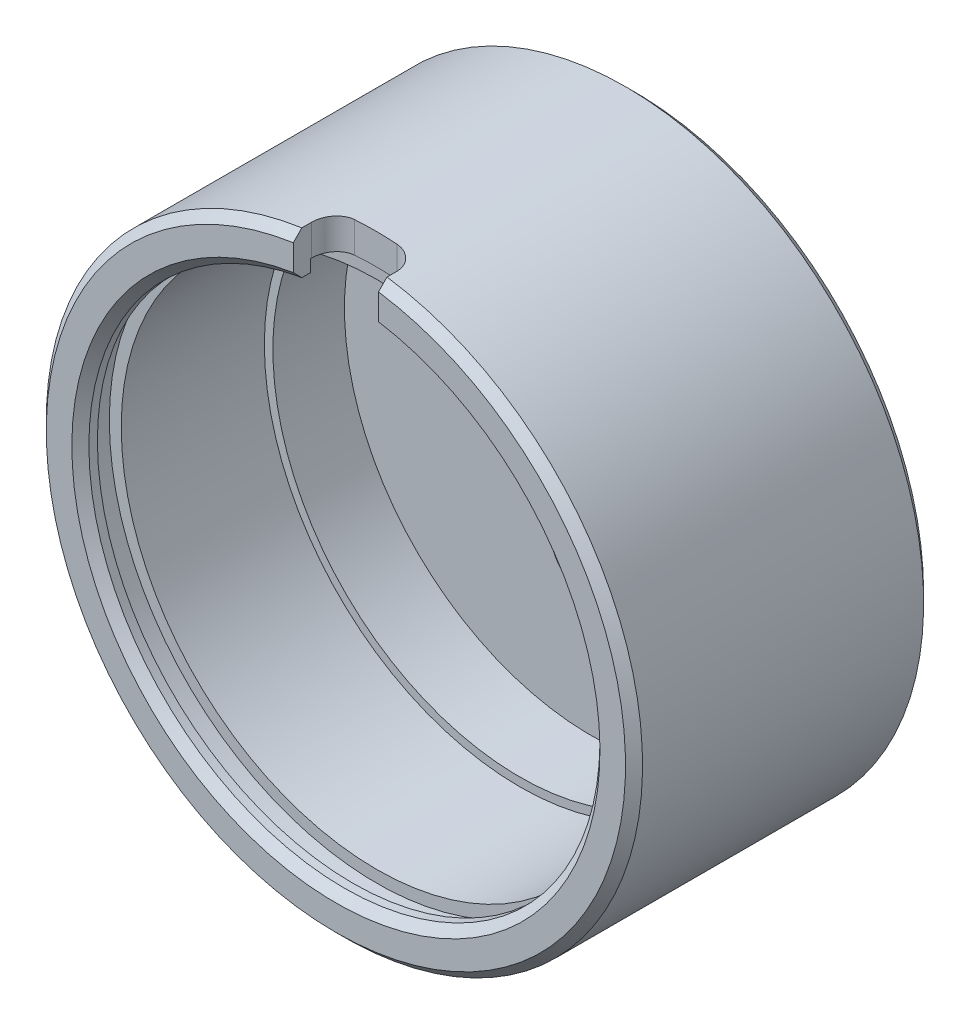
from build123d import *

# Parameters (mm, degrees)
CUT_EXTRUDE1_REACH                                   = 90.9
CHAMFER2_SIZE                                        = 1.27
CHAMFER3_SIZE                                        = 1.27
F_38_0_1015_DIAMETER_HOLE1_D                         = 2.5781
F_38_0_1015_DIAMETER_HOLE1_DEPTH                     = 0.254
F_38_0_1015_DIAMETER_HOLE1_TIP                       = 0.774539381
CBORE_FOR_3_8_BINDING_HEAD_MACHINE_SCREW_D           = 10.3124
CBORE_FOR_3_8_BINDING_HEAD_MACHINE_SCREW_DEPTH       = 6.35
CBORE_FOR_3_8_BINDING_HEAD_MACHINE_SCREW_CBORE_D     = 19.05
CBORE_FOR_3_8_BINDING_HEAD_MACHINE_SCREW_CBORE_DEPTH = 1.016
CUT_EXTRUDE3_REACH                                   = 46.45
SKETCH16_R                                           = 5.207
SKETCH16_R_2                                         = 3.3


with BuildPart() as part:
    # Sketch1 → Revolve1 (revolve)
    with BuildSketch(Plane(origin=(0, 0, 0), x_dir=(0, 0, -1), z_dir=(1, 0, 0))):
        Polygon((10.16, 0), (16.51, 0), (16.51, -44.45), (-27.94, -44.45), (-27.94, -38.1), (-25.4, -38.1), (-25.4, -39.878), (-21.844, -39.878), (-21.844, -38.1), (-0.508, -38.1), (-0.508, -36.83), (10.16, -36.83), align=None)
    revolve(axis=Axis((0, 0, 77.403157895), (0, 0, -1)))

    # Sketch2 → Cut-Extrude1 (cut, up to next)
    with BuildSketch(Plane(origin=(0, 44.45, 0), x_dir=(1, 0, 0), z_dir=(0, 1, 0)), mode=Mode.PRIVATE) as cut_extrude1_sk1:
        with BuildLine():
            Line((-6.35, -27.94), (6.35, -27.94))
            Line((6.35, -27.94), (6.35, -25.1968))
            ThreePointArc((6.35, -25.1968), (5.42006403, -22.95173597), (3.175, -22.0218))
            Line((3.175, -22.0218), (-3.175, -22.0218))
            ThreePointArc((-3.175, -22.0218), (-5.42006403, -22.95173597), (-6.35, -25.1968))
            Line((-6.35, -25.1968), (-6.35, -27.94))
        make_face()
    cut_extrude1_tool1 = extrude(cut_extrude1_sk1.sketch, amount=-CUT_EXTRUDE1_REACH, mode=Mode.PRIVATE) & part.part
    add(cut_extrude1_tool1.solids().sort_by_distance((0, 44.45, 25.118327))[0], mode=Mode.SUBTRACT)

    # Chamfer2
    chamfer2_edges = [part.edges().sort_by_distance(p)[0] for p in [
        (0, 44.45, -16.51),
        (-44.335876123, -3.183172689, 27.94),
    ]]
    chamfer(chamfer2_edges, length=CHAMFER2_SIZE)

    # Chamfer3
    chamfer3_edges = [part.edges().sort_by_distance(p)[0] for p in [
        (0, -38.1, 27.94),
    ]]
    chamfer(chamfer3_edges, length=CHAMFER3_SIZE)

    # #38 (0.1015) Diameter Hole1
    with Locations(Plane.XY.offset(-10.16)):
        with Locations((0, 0)):
            Hole(F_38_0_1015_DIAMETER_HOLE1_D / 2, depth=F_38_0_1015_DIAMETER_HOLE1_DEPTH)
            with Locations((0, 0, -(F_38_0_1015_DIAMETER_HOLE1_DEPTH + F_38_0_1015_DIAMETER_HOLE1_TIP / 2))):  # 118° drill point
                Cone(0, F_38_0_1015_DIAMETER_HOLE1_D / 2, F_38_0_1015_DIAMETER_HOLE1_TIP, mode=Mode.SUBTRACT)

    # CBORE for 3/8 Binding Head Machine Screw1
    with Locations(Plane(origin=(0, 0, -16.51), x_dir=(-1, 0, 0), z_dir=(0, 0, -1))):
        with Locations((-24.13512246, 0)):
            CounterBoreHole(CBORE_FOR_3_8_BINDING_HEAD_MACHINE_SCREW_D / 2, CBORE_FOR_3_8_BINDING_HEAD_MACHINE_SCREW_CBORE_D / 2, CBORE_FOR_3_8_BINDING_HEAD_MACHINE_SCREW_CBORE_DEPTH, depth=CBORE_FOR_3_8_BINDING_HEAD_MACHINE_SCREW_DEPTH)

    # Sketch16 → Cut-Extrude3 (cut, up to next)
    with BuildSketch(Plane(origin=(0, 0, -16.51), x_dir=(-1, 0, 0), z_dir=(0, 0, -1)), mode=Mode.PRIVATE) as cut_extrude3_sk1:
        with Locations((0.800871739, -13.932849809)):
            Circle(SKETCH16_R)
    cut_extrude3_tool1 = extrude(cut_extrude3_sk1.sketch, amount=-CUT_EXTRUDE3_REACH, mode=Mode.PRIVATE) & part.part
    add(cut_extrude3_tool1.solids().sort_by_distance((-0.800872, -13.93285, -16.51))[0], mode=Mode.SUBTRACT)
    # Sketch16 → Cut-Extrude3 (cut, up to next)
    with BuildSketch(Plane(origin=(0, 0, -16.51), x_dir=(-1, 0, 0), z_dir=(0, 0, -1)), mode=Mode.PRIVATE) as cut_extrude3_sk2:
        with Locations((6.332326955, 14.108828715)):
            Circle(SKETCH16_R_2)
    cut_extrude3_tool2 = extrude(cut_extrude3_sk2.sketch, amount=-CUT_EXTRUDE3_REACH, mode=Mode.PRIVATE) & part.part
    add(cut_extrude3_tool2.solids().sort_by_distance((-6.332327, 14.108829, -16.51))[0], mode=Mode.SUBTRACT)


solid = part.part
